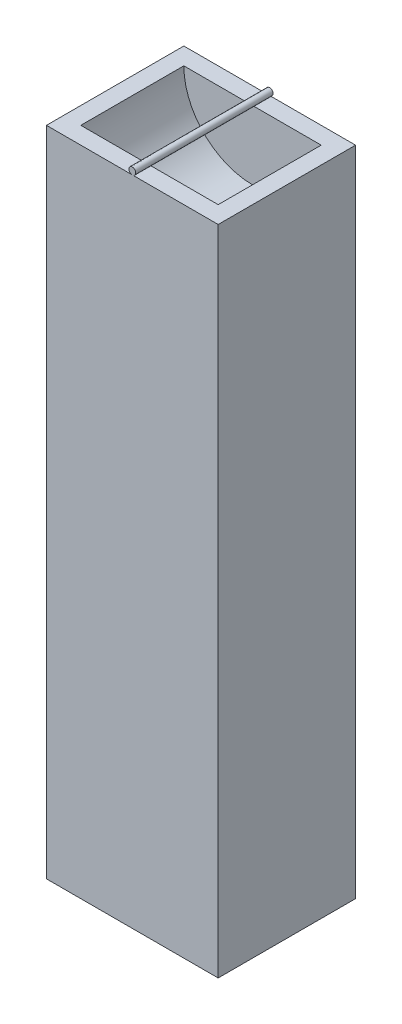
from build123d import *

# Parameters (mm, degrees)
SKETCH1_W           = 25
SKETCH1_H           = 95
BOSS_EXTRUDE1_DEPTH = 10
SKETCH2_R           = 10
CUT_EXTRUDE1_DEPTH  = 7.5
SWEEP1_PROFILE_R    = 0.5


with BuildPart() as part:
    # Sketch1 → Boss-Extrude1 (new body, symmetric)
    with BuildSketch(Plane.XY):
        with Locations((-37.921146953, 2.311827957)):
            Rectangle(SKETCH1_W, SKETCH1_H)
    extrude(amount=BOSS_EXTRUDE1_DEPTH, both=True)

    # Sketch2 → Cut-Extrude1 (cut, symmetric)
    with BuildSketch(Plane.XY):
        with Locations((-37.921146953, 49.811827957)):
            Circle(SKETCH2_R)
    extrude(amount=CUT_EXTRUDE1_DEPTH, both=True, mode=Mode.SUBTRACT)

    # Sweep1: sweep along a path in Sketch4
    with BuildLine(Plane.ZY.offset(37.921146953)) as sweep1_path:
        Line((-10, 50.309963159), (10, 50.309963159))
    # Sweep1 profile (on start of the path) → Sweep1 (sweep)
    with BuildSketch(Plane(origin=(-37.921146953, 50.309963159, -10), x_dir=(1, 0, 0), z_dir=(0, 0, 1))):
        Circle(SWEEP1_PROFILE_R)
    sweep(path=sweep1_path.line)


solid = part.part
